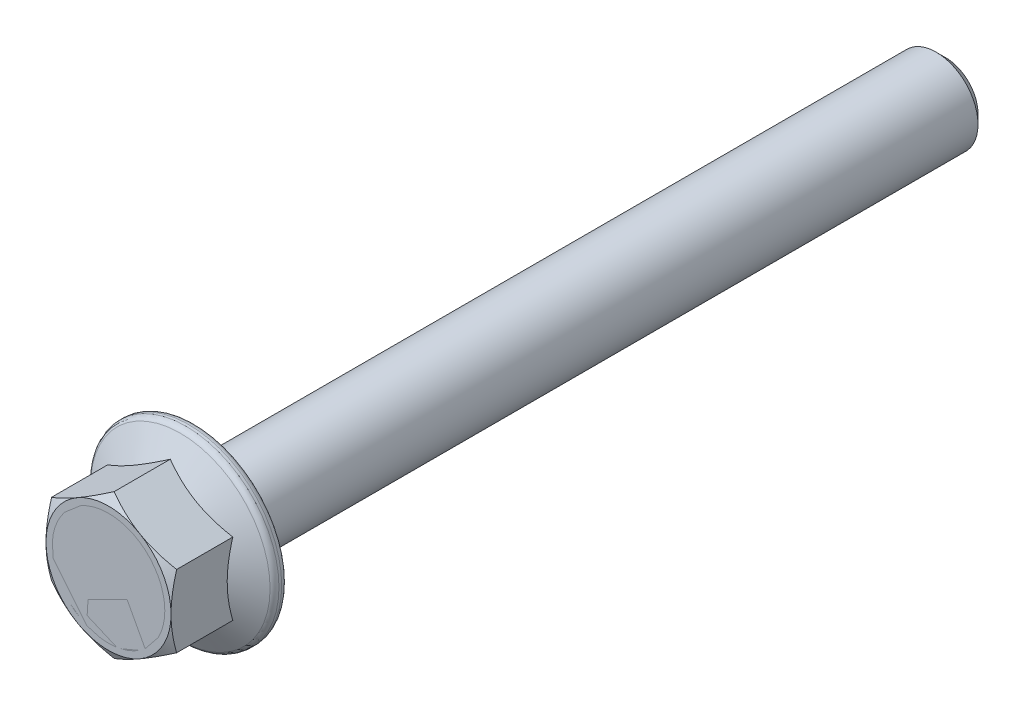
from build123d import *

# Parameters (mm, degrees)
BOSS_EXTRUDE1_REACH = 103.631
SKETCH4_OUTSIDE_W   = 400.87
SKETCH4_OUTSIDE_H   = 400.87
SKETCH4_OUTSIDE_R   = 7.5
CUT_EXTRUDE1_DEPTH  = 102.630728621
CUT_EXTRUDE1_DRAFT  = -60
FILLET1_R           = 0.78
SKETCH5_R           = 6.75
BOSS_EXTRUDE3_DEPTH = 0.375
BOSS_EXTRUDE3_DRAFT = -45
SKETCH8_W           = 0.480308949
SKETCH8_H           = 0.660424805
BOSS_EXTRUDE4_DEPTH = 0.625


with BuildPart() as part:
    # Sketch2 → Revolve1 (revolve)
    with BuildSketch(Plane(origin=(0, 0, 0), x_dir=(0, 0, -1), z_dir=(1, 0, 0)), mode=Mode.PRIVATE) as revolve1_sk:
        Polygon((-50.2, 0), (50.2, 0), (50.2, 3.875), (49.075, 5), (-39.8, 5), (-39.8, 11.15), (-41.36, 11.15), (-43.467328483, 7.5), (-50.2, 7.5), align=None)
    revolve(revolve1_sk.sketch.rotate(Axis((0, 0, 50.2), (0, 0, -1)), 90), axis=Axis((0, 0, 50.2), (0, 0, -1)))

    # Boss-Extrude1: up to this cone (the profile starts outside it)
    boss_extrude1_end = Plane(origin=(0, 0, 50.2), z_dir=(0, 0, -1)).offset(2.402545499) * Cone(1.732e-06, 176.198853504, 101.728454501, align=(Align.CENTER, Align.CENTER, Align.MIN), mode=Mode.PRIVATE)
    # Sketch3 → Boss-Extrude1 (add, up to the surface)
    with BuildSketch(Plane.XY.offset(50.2), mode=Mode.PRIVATE) as boss_extrude1_sk1:
        Polygon((0, 8.660254038), (-7.5, 4.330127019), (-7.5, -4.330127019), (0, -8.660254038), (7.5, -4.330127019), (7.5, 4.330127019), align=None)
    boss_extrude1_tool1 = extrude(boss_extrude1_sk1.sketch, amount=-BOSS_EXTRUDE1_REACH, mode=Mode.PRIVATE) - boss_extrude1_end
    add(boss_extrude1_tool1.solids().sort_by_distance((0, 0, 50.2))[0])


with BuildPart() as cut_extrude1_tool:
    # Sketch4 outside → Cut-Extrude1 (with draft: the straight prism first)
    with BuildSketch(Plane.XY.offset(50.2)):
        Rectangle(SKETCH4_OUTSIDE_W, SKETCH4_OUTSIDE_H)
        Circle(SKETCH4_OUTSIDE_R, mode=Mode.SUBTRACT)
    extrude(amount=-CUT_EXTRUDE1_DEPTH)
    # Cut-Extrude1: the draft: its side faces are tilted about the plane it starts from
    cut_extrude1_sides = [cut_extrude1_tool.faces().sort_by_distance(p)[0] for p in [
        (0, -200.435, -1.11536431),
        (200.435, 0, -1.11536431),
        (0, 200.435, -1.11536431),
        (-200.435, 0, -1.11536431),
        (-7.5, 0, -1.11536431),
    ]]
    draft(cut_extrude1_sides, Plane.XY.offset(50.2), CUT_EXTRUDE1_DRAFT)


with BuildPart() as part_1:
    add(part.part)

    # Cut-Extrude1: cut by cut_extrude1_tool
    add(cut_extrude1_tool.part, mode=Mode.SUBTRACT)

    # Fillet1
    fillet1_edges = [part_1.edges().sort_by_distance(p)[0] for p in [
        (-11.15, 0, 41.36),
        (-11.15, 0, 39.8),
    ]]
    fillet(fillet1_edges, radius=FILLET1_R)


with BuildPart() as body_2:
    # Sketch5 → Boss-Extrude3 (with draft: the straight prism first)
    with BuildSketch(Plane.XY.offset(50.2)):
        Circle(SKETCH5_R)
    extrude(amount=-BOSS_EXTRUDE3_DEPTH)
    # Boss-Extrude3: the draft: its side faces are tilted about the plane it starts from
    boss_extrude3_sides = [body_2.faces().sort_by_distance(p)[0] for p in [
        (-6.75, 0, 50.0125),
    ]]
    draft(boss_extrude3_sides, Plane.XY.offset(50.2), BOSS_EXTRUDE3_DRAFT)

    # Sketch8 → Boss-Extrude4 (add)
    with BuildSketch(Plane.XY.offset(50.2)):
        with BuildLine():
            Line((-3.802735874, -2.5), (-4.283044823, -2.5))
            Line((-4.283044823, -2.5), (-4.283044823, 1.162355735))
            add(Edge.make_bspline(
                [(-4.283044823, 1.162355735), (-4.312542349, 1.128401553), (-4.373675941, 1.058031544), (-4.479800723, 0.957955587), (-4.598065067, 0.854756857), (-4.728999398, 0.754617632), (-4.862411059, 0.658700458), (-4.994179867, 0.574339636), (-5.119367186, 0.500939361), (-5.203350209, 0.461042918), (-5.24366272, 0.441892312)],
                knots=[0, 0, 0, 0, 0.892555828, 1.849821039, 2.893015883, 4.008277588, 5.121255548, 6.154629642, 7.114207698, 8, 8, 8, 8], degree=3))
            Line((-5.24366272, 0.441892312), (-5.24366272, 0.982239879))
            add(Edge.make_bspline(
                [(-5.24366272, 0.982239879), (-5.178877262, 1.021230234), (-5.049861086, 1.098877079), (-4.869092539, 1.233386488), (-4.698322829, 1.378567281), (-4.542656219, 1.535940628), (-4.403273868, 1.698168989), (-4.283638791, 1.860073093), (-4.185545605, 2.019932733), (-4.137427758, 2.129897723), (-4.114186208, 2.183012251)],
                knots=[0, 0, 0, 0, 1.082272232, 2.155277244, 3.222407096, 4.289527553, 5.32168536, 6.282742408, 7.170542132, 8, 8, 8, 8], degree=3))
            Line((-4.114186208, 2.183012251), (-3.802735874, 2.183012251))
            Line((-3.802735874, 2.183012251), (-3.802735874, -2.5))
        make_face()
        with BuildLine():
            add(Edge.make_bspline(
                [(-2.601963502, -0.19038939), (-2.601200787, -0.095932152), (-2.599719779, 0.087481088), (-2.584413879, 0.353501226), (-2.560271943, 0.602023135), (-2.527442169, 0.832713576), (-2.483010936, 1.045607182), (-2.430688721, 1.24104551), (-2.366426606, 1.418407046), (-2.294095628, 1.578452305), (-2.21114863, 1.720287642), (-2.119703073, 1.844400447), (-2.017046348, 1.948776374), (-1.906009093, 2.035569022), (-1.784382365, 2.101689827), (-1.653897297, 2.149209504), (-1.514071529, 2.177884815), (-1.417586857, 2.181279952), (-1.36835751, 2.183012251)],
                knots=[0, 0, 0, 0, 1.522295809, 2.955932353, 4.292935845, 5.545987552, 6.709403679, 7.796379217, 8.803980711, 9.746667296, 10.623167879, 11.447716403, 12.224665142, 12.975696349, 13.710987297, 14.4460191, 15.207112772, 16, 16, 16, 16], degree=3))
            add(Edge.make_bspline(
                [(-1.36835751, 2.183012251), (-1.324486299, 2.181604891), (-1.238333281, 2.178841158), (-1.112614236, 2.156049859), (-0.994367352, 2.117276526), (-0.883503312, 2.063393142), (-0.780358879, 1.993824845), (-0.683919242, 1.909708093), (-0.595241224, 1.809346915), (-0.543891773, 1.733952074), (-0.517497712, 1.695198475)],
                knots=[0, 0, 0, 0, 1.02435884, 2.0116063, 2.972586715, 3.92329494, 4.881606269, 5.870473939, 6.905405214, 8, 8, 8, 8], degree=3))
            add(Edge.make_bspline(
                [(-0.517497712, 1.695198475), (-0.486945833, 1.642949847), (-0.423409977, 1.534293313), (-0.347545082, 1.352241675), (-0.283597974, 1.148905281), (-0.229680372, 0.923636987), (-0.191219713, 0.675972306), (-0.16078046, 0.406874624), (-0.143163713, 0.115667541), (-0.14133025, -0.085923664), (-0.140380139, -0.19038939)],
                knots=[0, 0, 0, 0, 0.745747152, 1.550859881, 2.42529298, 3.372802996, 4.404287875, 5.514077945, 6.711780846, 8, 8, 8, 8], degree=3))
            add(Edge.make_bspline(
                [(-0.140380139, -0.19038939), (-0.141133608, -0.284222427), (-0.142596378, -0.466388106), (-0.158055451, -0.731141345), (-0.181875729, -0.978455591), (-0.215151407, -1.208442429), (-0.259170582, -1.420813373), (-0.31218801, -1.616198555), (-0.374444592, -1.794511461), (-0.447776785, -1.954573786), (-0.529502734, -2.097236638), (-0.622499559, -2.220091748), (-0.722682254, -2.326333226), (-0.835160826, -2.411245958), (-0.955957671, -2.479238312), (-1.087322139, -2.525957073), (-1.227614003, -2.555034291), (-1.32443314, -2.558344448), (-1.373986131, -2.560038619)],
                knots=[0, 0, 0, 0, 1.513874866, 2.939007974, 4.277477108, 5.521918538, 6.686610019, 7.774777114, 8.786532326, 9.730252297, 10.61206932, 11.433487149, 12.211385775, 12.960169701, 13.698700869, 14.439280195, 15.201208188, 16, 16, 16, 16], degree=3))
            add(Edge.make_bspline(
                [(-1.373986131, -2.560038619), (-1.418183565, -2.558379724), (-1.505080694, -2.555118151), (-1.632581645, -2.530319831), (-1.753254339, -2.487562936), (-1.867736213, -2.428821627), (-1.976179461, -2.353721376), (-2.077259102, -2.26068028), (-2.173417252, -2.152147499), (-2.263497412, -2.026122113), (-2.344898545, -1.879364632), (-2.41370864, -1.708381977), (-2.472332732, -1.513990874), (-2.518853785, -1.295406521), (-2.558010532, -1.053522335), (-2.582619043, -0.787125101), (-2.598929857, -0.496728886), (-2.600925874, -0.295169746), (-2.601963502, -0.19038939)],
                knots=[0, 0, 0, 0, 0.713782411, 1.403376538, 2.088831486, 2.775699897, 3.476400496, 4.213162367, 4.989742879, 5.815463779, 6.710980744, 7.6941898, 8.787315853, 9.987366569, 11.302150399, 12.743876293, 14.307306722, 16, 16, 16, 16], degree=3))
        make_face()
        with BuildLine():
            add(Edge.make_bspline(
                [(-2.121654553, -0.188513184), (-2.120817042, -0.278577556), (-2.119217146, -0.450627239), (-2.110424787, -0.697521009), (-2.093806373, -0.920960472), (-2.070725093, -1.121649663), (-2.041461828, -1.298759589), (-2.005344225, -1.453265369), (-1.962306558, -1.584538757), (-1.911672731, -1.694448837), (-1.855523327, -1.785688331), (-1.795548523, -1.863435164), (-1.733536448, -1.93086238), (-1.665748816, -1.98472305), (-1.59537251, -2.028273194), (-1.519688071, -2.056689767), (-1.441365174, -2.077200642), (-1.387256134, -2.078880719), (-1.359914579, -2.07972967)],
                knots=[0, 0, 0, 0, 1.930873368, 3.688541263, 5.295281011, 6.732986767, 8.018032389, 9.141589856, 10.131594649, 10.974379403, 11.729767228, 12.422984227, 13.077418253, 13.687793181, 14.274134012, 14.843047171, 15.415386244, 16, 16, 16, 16], degree=3))
            add(Edge.make_bspline(
                [(-1.359914579, -2.07972967), (-1.334141041, -2.078839545), (-1.282821826, -2.077067164), (-1.208014582, -2.056765693), (-1.135896956, -2.026985698), (-1.067680981, -1.983886452), (-1.003464616, -1.928452429), (-0.942377525, -1.861150506), (-0.88432875, -1.781906692), (-0.828663454, -1.689299017), (-0.778567596, -1.578830563), (-0.735957235, -1.446933377), (-0.700102942, -1.292477161), (-0.670445018, -1.11545941), (-0.648958782, -0.915563694), (-0.631756867, -0.693473721), (-0.623192786, -0.448433726), (-0.621547586, -0.277637828), (-0.620689088, -0.188513184)],
                knots=[0, 0, 0, 0, 0.556098029, 1.107279675, 1.665020537, 2.239289732, 2.843790749, 3.494855459, 4.20099618, 4.965402842, 5.827994078, 6.818278647, 7.958442113, 9.254955883, 10.697998423, 12.305588537, 14.072183745, 16, 16, 16, 16], degree=3))
            add(Edge.make_bspline(
                [(-0.620689088, -0.188513184), (-0.621543765, -0.098449884), (-0.623182384, 0.074222678), (-0.631785532, 0.321443076), (-0.648705483, 0.545476422), (-0.671378402, 0.745916483), (-0.701202589, 0.923219797), (-0.736604868, 1.077617716), (-0.780346229, 1.208626962), (-0.830260985, 1.318317813), (-0.887553236, 1.408745646), (-0.946049783, 1.487672537), (-1.010153531, 1.553431502), (-1.077533494, 1.608188508), (-1.149170989, 1.65085716), (-1.225380375, 1.681347369), (-1.305569136, 1.699694917), (-1.360446023, 1.701696296), (-1.388057682, 1.702703303)],
                knots=[0, 0, 0, 0, 1.926173374, 3.692928135, 5.28908838, 6.72993665, 8.005261178, 9.132588719, 10.113846285, 10.954579593, 11.702439438, 12.399284011, 13.051919516, 13.660808713, 14.251466784, 14.827675714, 15.41013748, 16, 16, 16, 16], degree=3))
            add(Edge.make_bspline(
                [(-1.388057682, 1.702703303), (-1.413835417, 1.701836692), (-1.464859173, 1.700121346), (-1.539044441, 1.679734311), (-1.610214231, 1.649925045), (-1.67793049, 1.606634086), (-1.741338749, 1.550418838), (-1.80292122, 1.483533753), (-1.859696904, 1.403575274), (-1.915566328, 1.311815378), (-1.964783689, 1.201051467), (-2.007460156, 1.069383727), (-2.041784341, 0.914650426), (-2.0721153, 0.73816533), (-2.093326967, 0.538525065), (-2.110604643, 0.316451139), (-2.119145717, 0.07140627), (-2.120794294, -0.099388912), (-2.121654553, -0.188513184)],
                knots=[0, 0, 0, 0, 0.557102101, 1.102712893, 1.655222221, 2.224793741, 2.834805151, 3.487045402, 4.190458401, 4.956245252, 5.811421647, 6.809929224, 7.950602775, 9.242777249, 10.688425301, 12.298918027, 14.068702942, 16, 16, 16, 16], degree=3))
        make_face(mode=Mode.SUBTRACT)
        with Locations((0.820237759, -2.169787598)):
            Rectangle(SKETCH8_W, SKETCH8_H)
        with BuildLine():
            Line((1.900932894, -1.419304865), (2.381241843, -1.359266246))
            add(Edge.make_bspline(
                [(2.381241843, -1.359266246), (2.390846971, -1.415852951), (2.409017119, -1.522898766), (2.455251184, -1.670365739), (2.512668527, -1.796409063), (2.584450791, -1.900206009), (2.670350672, -1.981174454), (2.769680158, -2.039033882), (2.88210697, -2.073876083), (2.961363143, -2.077737064), (3.002266304, -2.07972967)],
                knots=[0, 0, 0, 0, 1.309725382, 2.477624782, 3.519252249, 4.462492528, 5.34180128, 6.193195808, 7.067530017, 8, 8, 8, 8], degree=3))
            add(Edge.make_bspline(
                [(3.002266304, -2.07972967), (3.039992531, -2.077728992), (3.114788461, -2.073762454), (3.223665151, -2.042284402), (3.326321182, -1.991210758), (3.407306482, -1.934013187), (3.467103967, -1.875645557), (3.512927352, -1.825196098), (3.554707444, -1.764941265), (3.595875772, -1.698140354), (3.634238391, -1.622842733), (3.67199276, -1.540839203), (3.706000991, -1.450141827), (3.752338996, -1.318250423), (3.80016589, -1.139078863), (3.839673621, -0.90924325), (3.864430733, -0.662794631), (3.867494471, -0.492832381), (3.86907386, -0.405215073)],
                knots=[0, 0, 0, 0, 0.871681479, 1.728193698, 2.598433288, 3.51585727, 4.0070026, 4.529633168, 5.089671721, 5.700050678, 6.343889226, 7.043128753, 7.787355008, 8.583454758, 10.276770505, 12.068987891, 13.973522342, 16, 16, 16, 16], degree=3))
            Line((3.86907386, -0.405215073), (3.86907386, -0.291704559))
            add(Edge.make_bspline(
                [(3.86907386, -0.291704559), (3.843940146, -0.335296757), (3.79433197, -0.421337738), (3.700929541, -0.536137266), (3.596193609, -0.637444531), (3.480591364, -0.723538016), (3.357362858, -0.791209627), (3.232076406, -0.842230051), (3.104377264, -0.872473817), (3.018677863, -0.876801903), (2.975999408, -0.878957298)],
                knots=[0, 0, 0, 0, 1.076943371, 2.125638765, 3.158845653, 4.193572763, 5.204435146, 6.163898621, 7.085618246, 8, 8, 8, 8], degree=3))
            add(Edge.make_bspline(
                [(2.975999408, -0.878957298), (2.938078388, -0.877671049), (2.863020165, -0.875125139), (2.752605368, -0.85551477), (2.64538737, -0.825086421), (2.543375347, -0.779089272), (2.44448233, -0.72259677), (2.350656929, -0.652335792), (2.260042348, -0.57019873), (2.174568178, -0.4760038), (2.095312767, -0.371128578), (2.027075605, -0.255512163), (1.969526214, -0.130635495), (1.922995732, 0.003380373), (1.885073734, 0.146230815), (1.859172664, 0.29881754), (1.844419987, 0.460673817), (1.842089991, 0.57163263), (1.840894275, 0.628574892)],
                knots=[0, 0, 0, 0, 0.86465958, 1.711446896, 2.551263658, 3.400931007, 4.257488752, 5.144979063, 6.069240711, 7.043889745, 8.042652401, 9.063041585, 10.100422143, 11.174417838, 12.295707709, 13.468554313, 14.700903177, 16, 16, 16, 16], degree=3))
            add(Edge.make_bspline(
                [(1.840894275, 0.628574892), (1.84198035, 0.687091908), (1.844104397, 0.801534289), (1.860473337, 0.968234042), (1.885524515, 1.125769421), (1.925233788, 1.272719348), (1.971884728, 1.411218006), (2.031762921, 1.539392316), (2.101078813, 1.658666857), (2.181840789, 1.766766838), (2.269476752, 1.864173649), (2.363004979, 1.949064927), (2.460365274, 2.022257923), (2.563875188, 2.080410369), (2.671030059, 2.127456181), (2.783592431, 2.158546534), (2.90016873, 2.179543506), (2.979656343, 2.181842695), (3.020090269, 2.183012251)],
                knots=[0, 0, 0, 0, 1.28857615, 2.520082744, 3.686305779, 4.797202427, 5.868826455, 6.901108228, 7.907493629, 8.90202596, 9.867517396, 10.788992686, 11.680218227, 12.543873392, 13.398473814, 14.25085117, 15.110239307, 16, 16, 16, 16], degree=3))
            add(Edge.make_bspline(
                [(3.020090269, 2.183012251), (3.048898805, 2.182311763), (3.106422301, 2.180913061), (3.191700223, 2.168981918), (3.275601888, 2.151476168), (3.358004948, 2.125989213), (3.438344495, 2.091912844), (3.517465672, 2.051149061), (3.595930224, 2.00455247), (3.67128977, 1.948868741), (3.744897496, 1.887112067), (3.814181853, 1.817665499), (3.878849356, 1.741044769), (3.940581562, 1.658772272), (3.995081849, 1.567610795), (4.048390812, 1.471232676), (4.095711868, 1.366895277), (4.139423153, 1.255263901), (4.178170379, 1.133761459), (4.21178384, 1.000644546), (4.239326387, 0.854877429), (4.263062736, 0.696900463), (4.280158047, 0.526239697), (4.293544191, 0.342947694), (4.300688884, 0.147071766), (4.301869641, 0.012245957), (4.302477638, -0.057178705)],
                knots=[0, 0, 0, 0, 0.71982096, 1.437303798, 2.148671553, 2.860726122, 3.5894893, 4.327127712, 5.084546776, 5.867862187, 6.666549548, 7.484587174, 8.316328227, 9.17150421, 10.052303838, 10.968733071, 11.923593905, 12.913579202, 13.964198915, 15.109293659, 16.343376022, 17.671051532, 19.10143247, 20.629623286, 22.264521701, 24, 24, 24, 24], degree=3))
            add(Edge.make_bspline(
                [(4.302477638, -0.057178705), (4.301966191, -0.134736059), (4.300973907, -0.2852088), (4.292500975, -0.504514082), (4.278328508, -0.710319877), (4.260309525, -0.903200727), (4.23511536, -1.082242218), (4.203762713, -1.247981972), (4.169313184, -1.40094107), (4.126535365, -1.540698898), (4.078817261, -1.668844531), (4.029897855, -1.788463291), (3.97524366, -1.898749839), (3.916189, -1.999689408), (3.854228925, -2.09267521), (3.787728801, -2.17618465), (3.71699067, -2.250764789), (3.642823616, -2.316584624), (3.565401269, -2.373984861), (3.485935777, -2.424030224), (3.403521814, -2.464987478), (3.320014011, -2.5007141), (3.232923584, -2.526328999), (3.144071132, -2.546577372), (3.052588356, -2.557833347), (2.991037042, -2.559300196), (2.96005165, -2.560038619)],
                knots=[0, 0, 0, 0, 1.764807986, 3.42398863, 4.99306403, 6.458696006, 7.831295522, 9.105472131, 10.296422921, 11.39714146, 12.428197542, 13.407419317, 14.336630445, 15.226313195, 16.067043525, 16.877164758, 17.652279824, 18.403342349, 19.130566392, 19.843339087, 20.537068434, 21.222906937, 21.90719335, 22.599498013, 23.294976811, 24, 24, 24, 24], degree=3))
            add(Edge.make_bspline(
                [(2.96005165, -2.560038619), (2.924972943, -2.559206352), (2.856087513, -2.557571998), (2.755073134, -2.542629167), (2.658356509, -2.520879068), (2.566318215, -2.488377029), (2.478625573, -2.446878185), (2.395232766, -2.396358513), (2.316606764, -2.336321207), (2.242320742, -2.267968168), (2.174194836, -2.190236059), (2.112710896, -2.104257352), (2.059104283, -2.009887591), (2.013500584, -1.907180293), (1.97403225, -1.79680604), (1.940887962, -1.678472057), (1.917014819, -1.551555554), (1.906378801, -1.464089615), (1.900932894, -1.419304865)],
                knots=[0, 0, 0, 0, 0.974221956, 1.913117753, 2.832138983, 3.725325793, 4.619357623, 5.523969086, 6.429456606, 7.364160882, 8.324683532, 9.296460859, 10.296689072, 11.335178463, 12.415402788, 13.551768977, 14.746444432, 16, 16, 16, 16], degree=3))
        make_face()
        with BuildLine():
            add(Edge.make_bspline(
                [(3.822168689, 0.640770236), (3.821411355, 0.680819495), (3.819929611, 0.75917685), (3.80948801, 0.873232938), (3.792952759, 0.981200347), (3.768563049, 1.082162385), (3.737838504, 1.17688896), (3.699091514, 1.264352161), (3.654077801, 1.345524028), (3.602483932, 1.419417828), (3.546664017, 1.485447531), (3.488185043, 1.543565433), (3.427103685, 1.592024869), (3.36493532, 1.633493181), (3.299815612, 1.664576565), (3.232261143, 1.686277333), (3.162903669, 1.699774888), (3.115835468, 1.701727797), (3.092324232, 1.702703303)],
                knots=[0, 0, 0, 0, 1.345999961, 2.633481834, 3.846522151, 5.014086171, 6.12088659, 7.189137531, 8.224301127, 9.236041944, 10.213065705, 11.127237019, 12.002136993, 12.83006775, 13.63396595, 14.418389675, 15.209963153, 16, 16, 16, 16], degree=3))
            add(Edge.make_bspline(
                [(3.092324232, 1.702703303), (3.067553603, 1.701810271), (3.018234721, 1.700032225), (2.945669465, 1.685447655), (2.874927113, 1.661732558), (2.806933713, 1.627571146), (2.740128918, 1.585030761), (2.67684395, 1.531790077), (2.614172929, 1.470479879), (2.555022799, 1.399653664), (2.499849498, 1.321546363), (2.451412307, 1.236246147), (2.411393708, 1.14427071), (2.378896558, 1.046166212), (2.351750282, 0.942321419), (2.335137553, 0.831615712), (2.323096188, 0.714831427), (2.321844789, 0.634863052), (2.321203224, 0.593865065)],
                knots=[0, 0, 0, 0, 0.795597862, 1.584053309, 2.369106213, 3.187177883, 4.023566861, 4.908945974, 5.83998388, 6.838605549, 7.870313796, 8.9100199, 9.985637853, 11.088521482, 12.229358934, 13.430623134, 14.682738284, 16, 16, 16, 16], degree=3))
            add(Edge.make_bspline(
                [(2.321203224, 0.593865065), (2.321988024, 0.556946239), (2.323520872, 0.484837426), (2.333564033, 0.379699119), (2.351751113, 0.280387342), (2.375745685, 0.186787581), (2.406723994, 0.09869524), (2.445276809, 0.016584872), (2.491552958, -0.059538811), (2.54365759, -0.129663616), (2.601145153, -0.192150829), (2.660711693, -0.248389263), (2.724951108, -0.29414096), (2.791300126, -0.332036505), (2.859809674, -0.362860505), (2.932005084, -0.38280673), (3.006391219, -0.397104034), (3.057231006, -0.398129646), (3.082943198, -0.398648349)],
                knots=[0, 0, 0, 0, 1.270391188, 2.481292313, 3.629423926, 4.741182195, 5.802977916, 6.837826839, 7.856438293, 8.863562247, 9.838501743, 10.775102984, 11.676942478, 12.544429056, 13.402050266, 14.253371081, 15.116643449, 16, 16, 16, 16], degree=3))
            add(Edge.make_bspline(
                [(3.082943198, -0.398648349), (3.108305715, -0.397581833), (3.158381246, -0.395476114), (3.232089611, -0.383728963), (3.302122349, -0.361009968), (3.370216828, -0.332696936), (3.434330566, -0.293286092), (3.495272118, -0.246051558), (3.554227721, -0.191238216), (3.608885444, -0.127491967), (3.660146659, -0.056638346), (3.702597857, 0.023134522), (3.740726132, 0.108366466), (3.770469387, 0.201278537), (3.793792935, 0.301046605), (3.810704426, 0.407939587), (3.819652446, 0.522104061), (3.821313037, 0.600417614), (3.822168689, 0.640770236)],
                knots=[0, 0, 0, 0, 0.854962158, 1.688029758, 2.504410095, 3.330252108, 4.166776435, 5.030713634, 5.925137581, 6.873583428, 7.855774289, 8.86472059, 9.911937097, 10.998017063, 12.145369077, 13.361241875, 14.64032716, 16, 16, 16, 16], degree=3))
        make_face(mode=Mode.SUBTRACT)
    extrude(amount=-BOSS_EXTRUDE4_DEPTH)


solid = Compound([part_1.part, body_2.part])
